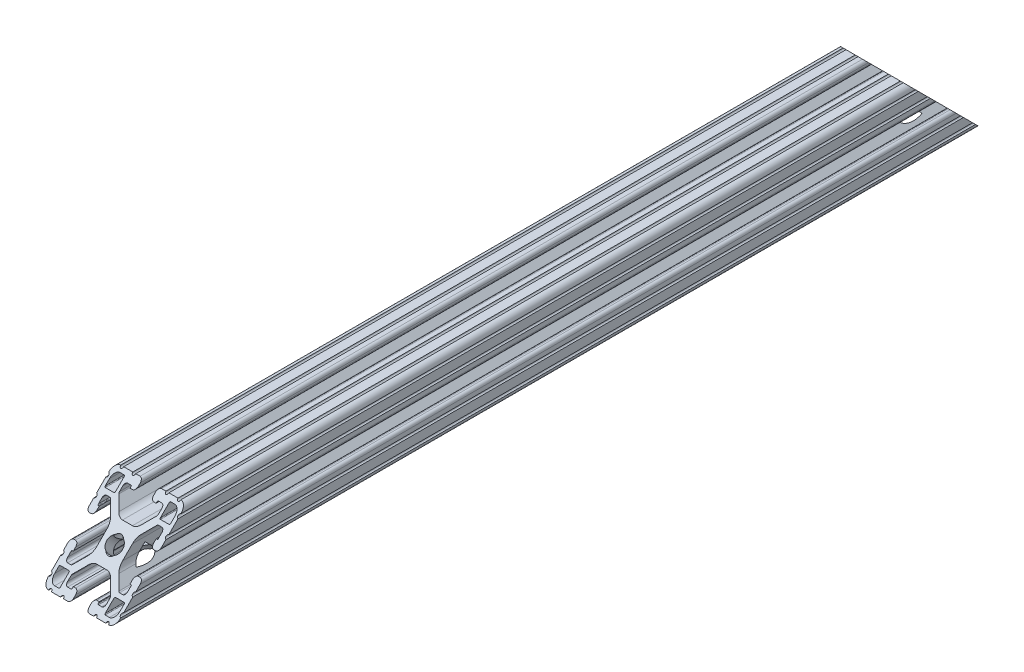
from build123d import *

# Parameters (mm, degrees)
SKETCH1_R          = 3.3274
EXTRUDE1_DEPTH     = 228.6
CUT_EXTRUDE1_DEPTH = 39.1
CUT_EXTRUDE2_START = -6.35
SKETCH3_R          = 4.1656
CUT_EXTRUDE2_DEPTH = 16.764
CUT_EXTRUDE3_START = -6.35
SKETCH4_R          = 9.525
CUT_EXTRUDE3_DEPTH = 37.592


with BuildPart() as part:
    # Sketch1 → Extrude1 (new body)
    with BuildSketch(Plane.XY):
        with BuildLine():
            Line((-15.4432, -6.858), (-14.986, -6.858))
            Line((-14.986, -6.858), (-14.986, -5.6388))
            ThreePointArc((-14.986, -5.6388), (-15.447248241, -4.525248241), (-16.5608, -4.064))
            Line((-16.5608, -4.064), (-17.4752, -4.064))
            ThreePointArc((-17.4752, -4.064), (-18.588751759, -4.525248241), (-19.05, -5.6388))
            Line((-19.05, -5.6388), (-19.05, -7.9756))
            ThreePointArc((-19.05, -7.9756), (-18.288, -8.7376), (-19.05, -9.4996))
            Line((-19.05, -9.4996), (-19.05, -14.3256))
            ThreePointArc((-19.05, -14.3256), (-18.288, -15.0876), (-19.05, -15.8496))
            Line((-19.05, -15.8496), (-19.05, -15.875))
            ThreePointArc((-19.05, -15.875), (-18.12006403, -18.12006403), (-15.875, -19.05))
            Line((-15.875, -19.05), (-15.8496, -19.05))
            ThreePointArc((-15.8496, -19.05), (-15.0876, -18.288), (-14.3256, -19.05))
            Line((-14.3256, -19.05), (-9.4996, -19.05))
            ThreePointArc((-9.4996, -19.05), (-8.7376, -18.288), (-7.9756, -19.05))
            Line((-7.9756, -19.05), (-5.6388, -19.05))
            ThreePointArc((-5.6388, -19.05), (-4.525248241, -18.588751759), (-4.064, -17.4752))
            Line((-4.064, -17.4752), (-4.064, -16.5608))
            ThreePointArc((-4.064, -16.5608), (-4.525248241, -15.447248241), (-5.6388, -14.986))
            Line((-5.6388, -14.986), (-6.858, -14.986))
            Line((-6.858, -14.986), (-6.858, -15.4432))
            ThreePointArc((-6.858, -15.4432), (-6.969592316, -15.712607684), (-7.239, -15.8242))
            Line((-7.239, -15.8242), (-9.017, -15.8242))
            ThreePointArc((-9.017, -15.8242), (-9.915025612, -15.452225612), (-10.287, -14.5542))
            Line((-10.287, -14.5542), (-10.287, -12.810497326))
            ThreePointArc((-10.287, -12.810497326), (-10.219328904, -12.470291755), (-10.026617928, -12.181879398))
            Line((-10.026617928, -12.181879398), (-5.973937506, -8.129198975))
            ThreePointArc((-5.973937506, -8.129198975), (-4.432991483, -7.09957176), (-2.615321716, -6.738014764))
            Line((-2.615321716, -6.738014764), (2.615321716, -6.738014764))
            ThreePointArc((2.615321716, -6.738014764), (4.432991483, -7.09957176), (5.973937506, -8.129198975))
            Line((5.973937506, -8.129198975), (10.026617928, -12.181879398))
            ThreePointArc((10.026617928, -12.181879398), (10.219328904, -12.470291755), (10.287, -12.810497326))
            Line((10.287, -12.810497326), (10.287, -14.5542))
            ThreePointArc((10.287, -14.5542), (9.915025612, -15.452225612), (9.017, -15.8242))
            Line((9.017, -15.8242), (7.239, -15.8242))
            ThreePointArc((7.239, -15.8242), (6.969592316, -15.712607684), (6.858, -15.4432))
            Line((6.858, -15.4432), (6.858, -14.986))
            Line((6.858, -14.986), (5.6388, -14.986))
            ThreePointArc((5.6388, -14.986), (4.525248241, -15.447248241), (4.064, -16.5608))
            Line((4.064, -16.5608), (4.064, -17.4752))
            ThreePointArc((4.064, -17.4752), (4.525248241, -18.588751759), (5.6388, -19.05))
            Line((5.6388, -19.05), (7.9756, -19.05))
            ThreePointArc((7.9756, -19.05), (8.7376, -18.288), (9.4996, -19.05))
            Line((9.4996, -19.05), (14.3256, -19.05))
            ThreePointArc((14.3256, -19.05), (15.0876, -18.288), (15.8496, -19.05))
            Line((15.8496, -19.05), (15.875, -19.05))
            ThreePointArc((15.875, -19.05), (18.12006403, -18.12006403), (19.05, -15.875))
            Line((19.05, -15.875), (19.05, -15.8496))
            ThreePointArc((19.05, -15.8496), (18.288, -15.0876), (19.05, -14.3256))
            Line((19.05, -14.3256), (19.05, -9.4996))
            ThreePointArc((19.05, -9.4996), (18.288, -8.7376), (19.05, -7.9756))
            Line((19.05, -7.9756), (19.05, -5.6388))
            ThreePointArc((19.05, -5.6388), (18.588751759, -4.525248241), (17.4752, -4.064))
            Line((17.4752, -4.064), (16.5608, -4.064))
            ThreePointArc((16.5608, -4.064), (15.447248241, -4.525248241), (14.986, -5.6388))
            Line((14.986, -5.6388), (14.986, -6.858))
            Line((14.986, -6.858), (15.4432, -6.858))
            ThreePointArc((15.4432, -6.858), (15.712607684, -6.969592316), (15.8242, -7.239))
            Line((15.8242, -7.239), (15.8242, -9.017))
            ThreePointArc((15.8242, -9.017), (15.452225612, -9.915025612), (14.5542, -10.287))
            Line((14.5542, -10.287), (12.810497326, -10.287))
            ThreePointArc((12.810497326, -10.287), (12.470291755, -10.219328904), (12.181879398, -10.026617928))
            Line((12.181879398, -10.026617928), (8.129198975, -5.973937506))
            ThreePointArc((8.129198975, -5.973937506), (7.09957176, -4.432991483), (6.738014764, -2.615321716))
            Line((6.738014764, -2.615321716), (6.738014764, 2.615321716))
            ThreePointArc((6.738014764, 2.615321716), (7.09957176, 4.432991483), (8.129198975, 5.973937506))
            Line((8.129198975, 5.973937506), (12.181879398, 10.026617928))
            ThreePointArc((12.181879398, 10.026617928), (12.470291755, 10.219328904), (12.810497326, 10.287))
            Line((12.810497326, 10.287), (14.5542, 10.287))
            ThreePointArc((14.5542, 10.287), (15.452225612, 9.915025612), (15.8242, 9.017))
            Line((15.8242, 9.017), (15.8242, 7.239))
            ThreePointArc((15.8242, 7.239), (15.712607684, 6.969592316), (15.4432, 6.858))
            Line((15.4432, 6.858), (14.986, 6.858))
            Line((14.986, 6.858), (14.986, 5.6388))
            ThreePointArc((14.986, 5.6388), (15.447248241, 4.525248241), (16.5608, 4.064))
            Line((16.5608, 4.064), (17.4752, 4.064))
            ThreePointArc((17.4752, 4.064), (18.588751759, 4.525248241), (19.05, 5.6388))
            Line((19.05, 5.6388), (19.05, 7.9756))
            ThreePointArc((19.05, 7.9756), (18.288, 8.7376), (19.05, 9.4996))
            Line((19.05, 9.4996), (19.05, 14.3256))
            ThreePointArc((19.05, 14.3256), (18.288, 15.0876), (19.05, 15.8496))
            Line((19.05, 15.8496), (19.05, 15.875))
            ThreePointArc((19.05, 15.875), (18.12006403, 18.12006403), (15.875, 19.05))
            Line((15.875, 19.05), (15.8496, 19.05))
            ThreePointArc((15.8496, 19.05), (15.0876, 18.288), (14.3256, 19.05))
            Line((14.3256, 19.05), (9.4996, 19.05))
            ThreePointArc((9.4996, 19.05), (8.7376, 18.288), (7.9756, 19.05))
            Line((7.9756, 19.05), (5.6388, 19.05))
            ThreePointArc((5.6388, 19.05), (4.525248241, 18.588751759), (4.064, 17.4752))
            Line((4.064, 17.4752), (4.064, 16.5608))
            ThreePointArc((4.064, 16.5608), (4.525248241, 15.447248241), (5.6388, 14.986))
            Line((5.6388, 14.986), (6.858, 14.986))
            Line((6.858, 14.986), (6.858, 15.4432))
            ThreePointArc((6.858, 15.4432), (6.969592316, 15.712607684), (7.239, 15.8242))
            Line((7.239, 15.8242), (9.017, 15.8242))
            ThreePointArc((9.017, 15.8242), (9.915025612, 15.452225612), (10.287, 14.5542))
            Line((10.287, 14.5542), (10.287, 12.810497326))
            ThreePointArc((10.287, 12.810497326), (10.219328904, 12.470291755), (10.026617928, 12.181879398))
            Line((10.026617928, 12.181879398), (5.973937506, 8.129198975))
            ThreePointArc((5.973937506, 8.129198975), (4.432991483, 7.09957176), (2.615321716, 6.738014764))
            Line((2.615321716, 6.738014764), (-2.615321716, 6.738014764))
            ThreePointArc((-2.615321716, 6.738014764), (-4.432991483, 7.09957176), (-5.973937506, 8.129198975))
            Line((-5.973937506, 8.129198975), (-10.026617928, 12.181879398))
            ThreePointArc((-10.026617928, 12.181879398), (-10.219328904, 12.470291755), (-10.287, 12.810497326))
            Line((-10.287, 12.810497326), (-10.287, 14.5542))
            ThreePointArc((-10.287, 14.5542), (-9.915025612, 15.452225612), (-9.017, 15.8242))
            Line((-9.017, 15.8242), (-7.239, 15.8242))
            ThreePointArc((-7.239, 15.8242), (-6.969592316, 15.712607684), (-6.858, 15.4432))
            Line((-6.858, 15.4432), (-6.858, 14.986))
            Line((-6.858, 14.986), (-5.6388, 14.986))
            ThreePointArc((-5.6388, 14.986), (-4.525248241, 15.447248241), (-4.064, 16.5608))
            Line((-4.064, 16.5608), (-4.064, 17.4752))
            ThreePointArc((-4.064, 17.4752), (-4.525248241, 18.588751759), (-5.6388, 19.05))
            Line((-5.6388, 19.05), (-7.9756, 19.05))
            ThreePointArc((-7.9756, 19.05), (-8.7376, 18.288), (-9.4996, 19.05))
            Line((-9.4996, 19.05), (-14.3256, 19.05))
            ThreePointArc((-14.3256, 19.05), (-15.0876, 18.288), (-15.8496, 19.05))
            Line((-15.8496, 19.05), (-15.875, 19.05))
            ThreePointArc((-15.875, 19.05), (-18.12006403, 18.12006403), (-19.05, 15.875))
            Line((-19.05, 15.875), (-19.05, 15.8496))
            ThreePointArc((-19.05, 15.8496), (-18.288, 15.0876), (-19.05, 14.3256))
            Line((-19.05, 14.3256), (-19.05, 9.4996))
            ThreePointArc((-19.05, 9.4996), (-18.288, 8.7376), (-19.05, 7.9756))
            Line((-19.05, 7.9756), (-19.05, 5.6388))
            ThreePointArc((-19.05, 5.6388), (-18.588751759, 4.525248241), (-17.4752, 4.064))
            Line((-17.4752, 4.064), (-16.5608, 4.064))
            ThreePointArc((-16.5608, 4.064), (-15.447248241, 4.525248241), (-14.986, 5.6388))
            Line((-14.986, 5.6388), (-14.986, 6.858))
            Line((-14.986, 6.858), (-15.4432, 6.858))
            ThreePointArc((-15.4432, 6.858), (-15.712607684, 6.969592316), (-15.8242, 7.239))
            Line((-15.8242, 7.239), (-15.8242, 9.017))
            ThreePointArc((-15.8242, 9.017), (-15.452225612, 9.915025612), (-14.5542, 10.287))
            Line((-14.5542, 10.287), (-12.810497326, 10.287))
            ThreePointArc((-12.810497326, 10.287), (-12.470291755, 10.219328904), (-12.181879398, 10.026617928))
            Line((-12.181879398, 10.026617928), (-8.129198975, 5.973937506))
            ThreePointArc((-8.129198975, 5.973937506), (-7.09957176, 4.432991483), (-6.738014764, 2.615321716))
            Line((-6.738014764, 2.615321716), (-6.738014764, -2.615321716))
            ThreePointArc((-6.738014764, -2.615321716), (-7.09957176, -4.432991483), (-8.129198975, -5.973937506))
            Line((-8.129198975, -5.973937506), (-12.181879398, -10.026617928))
            ThreePointArc((-12.181879398, -10.026617928), (-12.470291755, -10.219328904), (-12.810497326, -10.287))
            Line((-12.810497326, -10.287), (-14.5542, -10.287))
            ThreePointArc((-14.5542, -10.287), (-15.452225612, -9.915025612), (-15.8242, -9.017))
            Line((-15.8242, -9.017), (-15.8242, -7.239))
            ThreePointArc((-15.8242, -7.239), (-15.712607684, -6.969592316), (-15.4432, -6.858))
        make_face()
        Circle(SKETCH1_R, mode=Mode.SUBTRACT)
        with BuildLine():
            Line((16.8656, 11.8618), (12.2428, 11.8618))
            ThreePointArc((12.2428, 11.8618), (11.973392316, 11.973392316), (11.8618, 12.2428))
            Line((11.8618, 12.2428), (11.8618, 16.8656))
            ThreePointArc((11.8618, 16.8656), (11.973392316, 17.135007684), (12.2428, 17.2466))
            Line((12.2428, 17.2466), (14.4526, 17.2466))
            ThreePointArc((14.4526, 17.2466), (16.428256347, 16.428256347), (17.2466, 14.4526))
            Line((17.2466, 14.4526), (17.2466, 12.2428))
            ThreePointArc((17.2466, 12.2428), (17.135007684, 11.973392316), (16.8656, 11.8618))
        make_face(mode=Mode.SUBTRACT)
        with BuildLine():
            Line((-16.8656, -11.8618), (-12.2428, -11.8618))
            ThreePointArc((-12.2428, -11.8618), (-11.973392316, -11.973392316), (-11.8618, -12.2428))
            Line((-11.8618, -12.2428), (-11.8618, -16.8656))
            ThreePointArc((-11.8618, -16.8656), (-11.973392316, -17.135007684), (-12.2428, -17.2466))
            Line((-12.2428, -17.2466), (-14.4526, -17.2466))
            ThreePointArc((-14.4526, -17.2466), (-16.428256347, -16.428256347), (-17.2466, -14.4526))
            Line((-17.2466, -14.4526), (-17.2466, -12.2428))
            ThreePointArc((-17.2466, -12.2428), (-17.135007684, -11.973392316), (-16.8656, -11.8618))
        make_face(mode=Mode.SUBTRACT)
        with BuildLine():
            Line((11.8618, -16.8656), (11.8618, -12.2428))
            ThreePointArc((11.8618, -12.2428), (11.973392316, -11.973392316), (12.2428, -11.8618))
            Line((12.2428, -11.8618), (16.8656, -11.8618))
            ThreePointArc((16.8656, -11.8618), (17.135007684, -11.973392316), (17.2466, -12.2428))
            Line((17.2466, -12.2428), (17.2466, -14.4526))
            ThreePointArc((17.2466, -14.4526), (16.428256347, -16.428256347), (14.4526, -17.2466))
            Line((14.4526, -17.2466), (12.2428, -17.2466))
            ThreePointArc((12.2428, -17.2466), (11.973392316, -17.135007684), (11.8618, -16.8656))
        make_face(mode=Mode.SUBTRACT)
        with BuildLine():
            Line((-11.8618, 16.8656), (-11.8618, 12.2428))
            ThreePointArc((-11.8618, 12.2428), (-11.973392316, 11.973392316), (-12.2428, 11.8618))
            Line((-12.2428, 11.8618), (-16.8656, 11.8618))
            ThreePointArc((-16.8656, 11.8618), (-17.135007684, 11.973392316), (-17.2466, 12.2428))
            Line((-17.2466, 12.2428), (-17.2466, 14.4526))
            ThreePointArc((-17.2466, 14.4526), (-16.428256347, 16.428256347), (-14.4526, 17.2466))
            Line((-14.4526, 17.2466), (-12.2428, 17.2466))
            ThreePointArc((-12.2428, 17.2466), (-11.973392316, 17.135007684), (-11.8618, 16.8656))
        make_face(mode=Mode.SUBTRACT)
    extrude1 = extrude(amount=-EXTRUDE1_DEPTH)

    # Sketch2 → Cut-Extrude1 (cut, through all)
    with BuildSketch(Plane(origin=(19.05, 0, 0), x_dir=(0, 0, -1), z_dir=(1, 0, 0))):
        Polygon((0, -19.05), (0, 27.880063074), (46.930063074, 27.880063074), align=None)
    cut_extrude1 = extrude(amount=-CUT_EXTRUDE1_DEPTH, mode=Mode.SUBTRACT)

    # Sketch3 → Cut-Extrude2 (cut)
    with BuildSketch(Plane(origin=(0, -9.525, -9.525), x_dir=(1, 0, 0), z_dir=(0, 0.707106781, 0.707106781)).offset(CUT_EXTRUDE2_START)):
        with Locations((0, 13.470384182)):
            Circle(SKETCH3_R)
    cut_extrude2 = extrude(amount=CUT_EXTRUDE2_DEPTH, mode=Mode.SUBTRACT)

    # Sketch4 → Cut-Extrude3 (cut)
    with BuildSketch(Plane(origin=(0, -9.525, -9.525), x_dir=(1, 0, 0), z_dir=(0, 0.707106781, 0.707106781)).offset(CUT_EXTRUDE3_START)):
        with Locations((0, 13.470384182)):
            Circle(SKETCH4_R)
    cut_extrude3 = extrude(amount=-CUT_EXTRUDE3_DEPTH, mode=Mode.SUBTRACT)

    # Mirror1: Extrude1, Cut-Extrude1, Cut-Extrude2, Cut-Extrude3 across plane
    add(extrude1.mirror(Plane(origin=(-15.4432, -7.239, -228.6), x_dir=(1, 0, 0), z_dir=(0, 0, 1))))
    add(cut_extrude1.mirror(Plane(origin=(-15.4432, -7.239, -228.6), x_dir=(1, 0, 0), z_dir=(0, 0, 1))), mode=Mode.SUBTRACT)
    add(cut_extrude2.mirror(Plane(origin=(-15.4432, -7.239, -228.6), x_dir=(1, 0, 0), z_dir=(0, 0, 1))), mode=Mode.SUBTRACT)
    add(cut_extrude3.mirror(Plane(origin=(-15.4432, -7.239, -228.6), x_dir=(1, 0, 0), z_dir=(0, 0, 1))), mode=Mode.SUBTRACT)


solid = part.part
